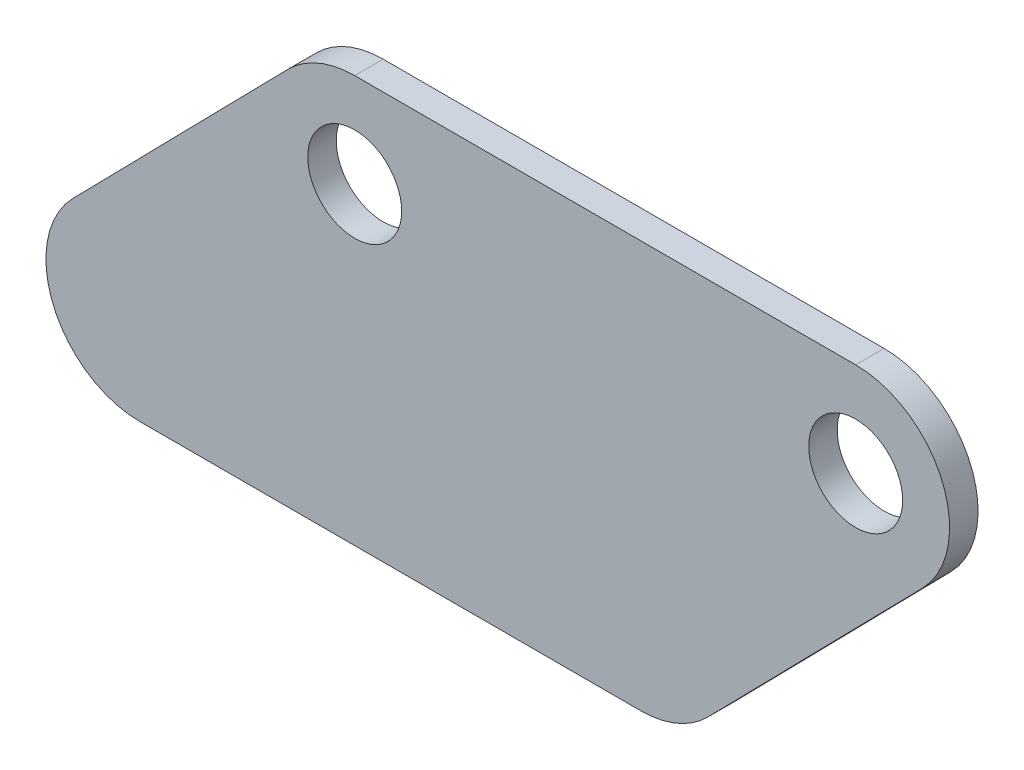
from build123d import *

# Parameters (mm, degrees)
SKETCH1_R           = 5.23875
BOSS_EXTRUDE1_DEPTH = 3.175


with BuildPart() as part:
    # Sketch1 → Boss-Extrude1 (new body)
    with BuildSketch(Plane.XY):
        with BuildLine():
            ThreePointArc((69.618228339, -7.33425), (71.795574408, 4.057918301), (62.135796703, 10.4775))
            Line((62.135796703, 10.4775), (6.255796703, 10.4775))
            ThreePointArc((6.255796703, 10.4775), (2.197878402, 9.659777705), (-1.226634933, 7.33425))
            Line((-1.226634933, 7.33425), (-25.189978081, -17.11325))
            ThreePointArc((-25.189978081, -17.11325), (-27.36732415, -28.505418301), (-17.707546445, -34.925))
            Line((-17.707546445, -34.925), (38.172453555, -34.925))
            ThreePointArc((38.172453555, -34.925), (42.230371798, -34.107277729), (45.654885103, -31.78175009))
            Line((45.654885103, -31.78175009), (69.618228339, -7.33425))
        make_face()
        with Locations((6.255796703, 0)):
            Circle(SKETCH1_R, mode=Mode.SUBTRACT)
        with Locations((62.135796703, 0)):
            Circle(SKETCH1_R, mode=Mode.SUBTRACT)
    extrude(amount=BOSS_EXTRUDE1_DEPTH)


solid = part.part
